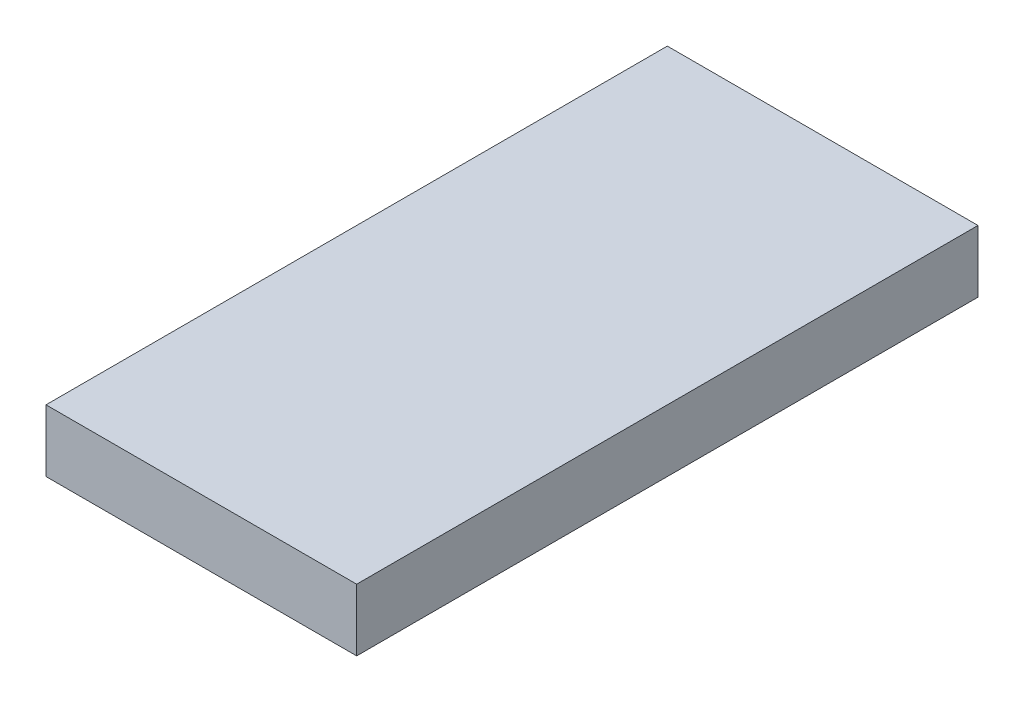
from build123d import *

# Parameters (mm, degrees)
SKETCH1_W           = 5
SKETCH1_H           = 1
BOSS_EXTRUDE1_DEPTH = 10


with BuildPart() as part:
    # Sketch1 → Boss-Extrude1 (new body)
    with BuildSketch(Plane.XY):
        with Locations((2.013096537, 0.375068693)):
            Rectangle(SKETCH1_W, SKETCH1_H)
    extrude(amount=BOSS_EXTRUDE1_DEPTH)


solid = part.part
